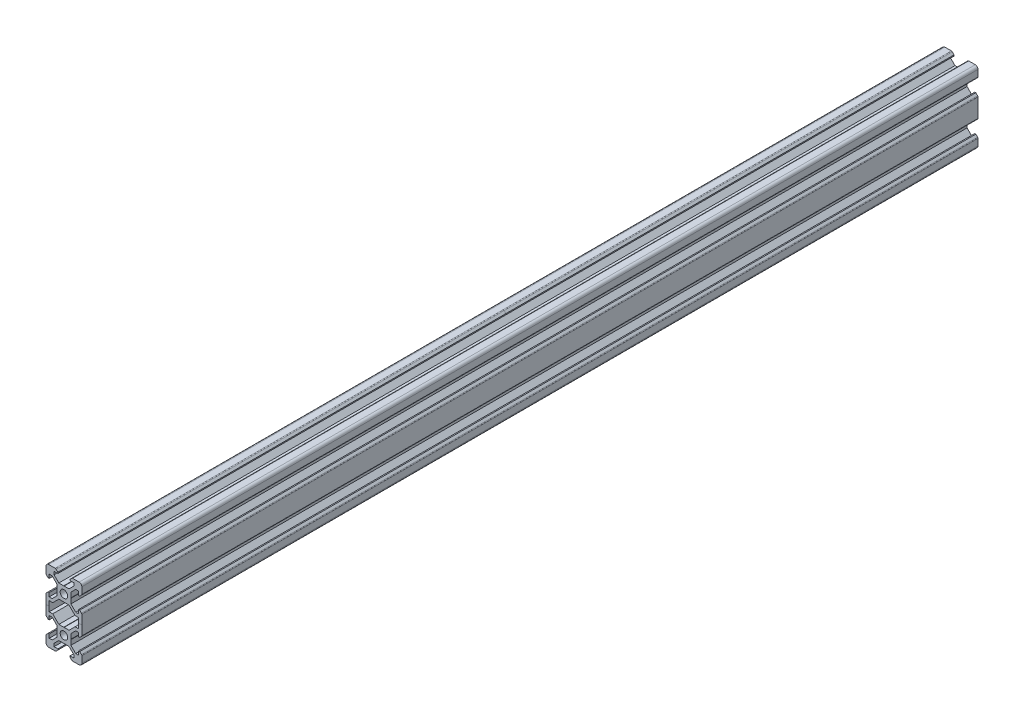
from build123d import *

# Parameters (mm, degrees)
SKETCH1_R           = 2.1
BOSS_EXTRUDE2_DEPTH = 500


with BuildPart() as part:
    # Sketch1 → Boss-Extrude2 (new body)
    with BuildSketch(Plane.XY):
        with BuildLine():
            Line((-8.5, 10), (-4.862792737, 10))
            ThreePointArc((-4.862792737, 10), (-4.598292737, 9.947387679), (-4.374060464, 9.797560464))
            Line((-4.374060464, 9.797560464), (-3.3865, 8.81))
            Line((-3.3865, 8.81), (-3.3865, 8.2))
            Line((-3.3865, 8.2), (-5.5, 8.2))
            Line((-5.5, 8.2), (-5.5, 6.561))
            Line((-5.5, 6.561), (-2.8395, 3.9005))
            Line((-2.8395, 3.9005), (-0.1, 3.9005))
            Line((-0.1, 3.9005), (0, 3.8005))
            Line((0, 3.8005), (0.1, 3.9005))
            Line((0.1, 3.9005), (2.8395, 3.9005))
            Line((2.8395, 3.9005), (5.5, 6.561))
            Line((5.5, 6.561), (5.5, 8.2))
            Line((5.5, 8.2), (3.3865, 8.2))
            Line((3.3865, 8.2), (3.3865, 8.81))
            Line((3.3865, 8.81), (4.374060464, 9.797560464))
            ThreePointArc((4.374060464, 9.797560464), (4.598292737, 9.947387679), (4.862792737, 10))
            Line((4.862792737, 10), (8.5, 10))
            ThreePointArc((8.5, 10), (9.560660172, 9.560660172), (10, 8.5))
            Line((10, 8.5), (10, 4.862792737))
            ThreePointArc((10, 4.862792737), (9.947387679, 4.598292737), (9.797560464, 4.374060464))
            Line((9.797560464, 4.374060464), (8.81, 3.3865))
            Line((8.81, 3.3865), (8.2, 3.3865))
            Line((8.2, 3.3865), (8.2, 5.5))
            Line((8.2, 5.5), (6.561, 5.5))
            Line((6.561, 5.5), (3.9005, 2.8395))
            Line((3.9005, 2.8395), (3.9005, 0.1))
            Line((3.9005, 0.1), (3.8005, 0))
            Line((3.8005, 0), (3.9005, -0.1))
            Line((3.9005, -0.1), (3.9005, -2.8395))
            Line((3.9005, -2.8395), (6.561, -5.5))
            Line((6.561, -5.5), (8.2, -5.5))
            Line((8.2, -5.5), (8.2, -3.3865))
            Line((8.2, -3.3865), (8.81, -3.3865))
            Line((8.81, -3.3865), (9.797560464, -4.374060464))
            ThreePointArc((9.797560464, -4.374060464), (9.947387679, -4.598292737), (10, -4.862792737))
            Line((10, -4.862792737), (10, -15.137207263))
            ThreePointArc((10, -15.137207263), (9.947387679, -15.401707263), (9.797560464, -15.625939536))
            Line((9.797560464, -15.625939536), (8.81, -16.6135))
            Line((8.81, -16.6135), (8.2, -16.6135))
            Line((8.2, -16.6135), (8.2, -14.5))
            Line((8.2, -14.5), (6.561, -14.5))
            Line((6.561, -14.5), (3.9005, -17.1605))
            Line((3.9005, -17.1605), (3.9005, -19.9))
            Line((3.9005, -19.9), (3.8005, -20))
            Line((3.8005, -20), (3.9005, -20.1))
            Line((3.9005, -20.1), (3.9005, -22.8395))
            Line((3.9005, -22.8395), (6.561, -25.5))
            Line((6.561, -25.5), (8.2, -25.5))
            Line((8.2, -25.5), (8.2, -23.3865))
            Line((8.2, -23.3865), (8.81, -23.3865))
            Line((8.81, -23.3865), (9.797560464, -24.374060464))
            ThreePointArc((9.797560464, -24.374060464), (9.947387679, -24.598292737), (10, -24.862792737))
            Line((10, -24.862792737), (10, -28.5))
            ThreePointArc((10, -28.5), (9.560660172, -29.560660172), (8.5, -30))
            Line((8.5, -30), (4.862792737, -30))
            ThreePointArc((4.862792737, -30), (4.598292737, -29.947387679), (4.374060464, -29.797560464))
            Line((4.374060464, -29.797560464), (3.3865, -28.81))
            Line((3.3865, -28.81), (3.3865, -28.2))
            Line((3.3865, -28.2), (5.5, -28.2))
            Line((5.5, -28.2), (5.5, -26.561))
            Line((5.5, -26.561), (2.8395, -23.9005))
            Line((2.8395, -23.9005), (0.1, -23.9005))
            Line((0.1, -23.9005), (0, -23.8005))
            Line((0, -23.8005), (-0.1, -23.9005))
            Line((-0.1, -23.9005), (-2.8395, -23.9005))
            Line((-2.8395, -23.9005), (-5.5, -26.561))
            Line((-5.5, -26.561), (-5.5, -28.2))
            Line((-5.5, -28.2), (-3.3865, -28.2))
            Line((-3.3865, -28.2), (-3.3865, -28.81))
            Line((-3.3865, -28.81), (-4.374060464, -29.797560464))
            ThreePointArc((-4.374060464, -29.797560464), (-4.598292737, -29.947387679), (-4.862792737, -30))
            Line((-4.862792737, -30), (-8.5, -30))
            ThreePointArc((-8.5, -30), (-9.560660172, -29.560660172), (-10, -28.5))
            Line((-10, -28.5), (-10, -24.862792737))
            ThreePointArc((-10, -24.862792737), (-9.947387679, -24.598292737), (-9.797560464, -24.374060464))
            Line((-9.797560464, -24.374060464), (-8.81, -23.3865))
            Line((-8.81, -23.3865), (-8.2, -23.3865))
            Line((-8.2, -23.3865), (-8.2, -25.5))
            Line((-8.2, -25.5), (-6.561, -25.5))
            Line((-6.561, -25.5), (-3.9005, -22.8395))
            Line((-3.9005, -22.8395), (-3.9005, -20.1))
            Line((-3.9005, -20.1), (-3.8005, -20))
            Line((-3.8005, -20), (-3.9005, -19.9))
            Line((-3.9005, -19.9), (-3.9005, -17.1605))
            Line((-3.9005, -17.1605), (-6.561, -14.5))
            Line((-6.561, -14.5), (-8.2, -14.5))
            Line((-8.2, -14.5), (-8.2, -16.6135))
            Line((-8.2, -16.6135), (-8.81, -16.6135))
            Line((-8.81, -16.6135), (-9.797560464, -15.625939536))
            ThreePointArc((-9.797560464, -15.625939536), (-9.947387679, -15.401707263), (-10, -15.137207263))
            Line((-10, -15.137207263), (-10, -4.862792737))
            ThreePointArc((-10, -4.862792737), (-9.947387679, -4.598292737), (-9.797560464, -4.374060464))
            Line((-9.797560464, -4.374060464), (-8.81, -3.3865))
            Line((-8.81, -3.3865), (-8.2, -3.3865))
            Line((-8.2, -3.3865), (-8.2, -5.5))
            Line((-8.2, -5.5), (-6.561, -5.5))
            Line((-6.561, -5.5), (-3.9005, -2.8395))
            Line((-3.9005, -2.8395), (-3.9005, -0.1))
            Line((-3.9005, -0.1), (-3.8005, 0))
            Line((-3.8005, 0), (-3.9005, 0.1))
            Line((-3.9005, 0.1), (-3.9005, 2.8395))
            Line((-3.9005, 2.8395), (-6.561, 5.5))
            Line((-6.561, 5.5), (-8.2, 5.5))
            Line((-8.2, 5.5), (-8.2, 3.3865))
            Line((-8.2, 3.3865), (-8.81, 3.3865))
            Line((-8.81, 3.3865), (-9.797560464, 4.374060464))
            ThreePointArc((-9.797560464, 4.374060464), (-9.947387679, 4.598292737), (-10, 4.862792737))
            Line((-10, 4.862792737), (-10, 8.5))
            ThreePointArc((-10, 8.5), (-9.560660172, 9.560660172), (-8.5, 10))
        make_face()
        Circle(SKETCH1_R, mode=Mode.SUBTRACT)
        with Locations((0, -20)):
            Circle(SKETCH1_R, mode=Mode.SUBTRACT)
        Polygon((-8.2, -12.7), (-8.2, -7.3), (-6.239, -7.3), (-5.5, -6.561), (-2.8395, -3.9005), (-0.1, -3.9005), (0, -3.8005), (0.1, -3.9005), (2.8395, -3.9005), (5.5, -6.561), (6.239, -7.3), (8.2, -7.3), (8.2, -12.7), (6.239, -12.7), (5.5, -13.439), (2.8395, -16.0995), (0.1, -16.0995), (0, -16.1995), (-0.1, -16.0995), (-2.8395, -16.0995), (-5.5, -13.439), (-6.239, -12.7), align=None, mode=Mode.SUBTRACT)
    extrude(amount=BOSS_EXTRUDE2_DEPTH)


solid = part.part
